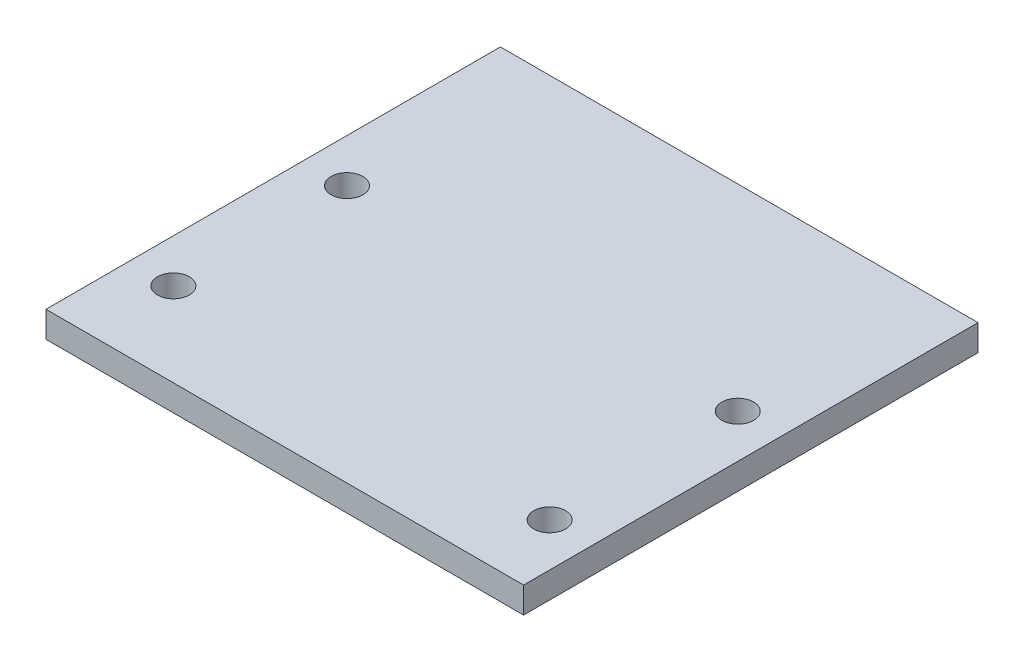
from build123d import *

# Parameters (mm, degrees)
SKETCH5_W      = 41.91
SKETCH5_H      = 39.878
SKETCH5_R      = 1.397
EXTRUDE3_DEPTH = 2.286


with BuildPart() as part:
    # Sketch5 → Extrude3 (new body)
    with BuildSketch(Plane(origin=(0, 0, 0), x_dir=(1, 0, 0), z_dir=(0, 1, 0))):
        with Locations((-20.955, -19.939)):
            Rectangle(SKETCH5_W, SKETCH5_H)
        with Locations((-38.1, -17.272)):
            Circle(SKETCH5_R, mode=Mode.SUBTRACT)
        with Locations((-38.1, -32.512)):
            Circle(SKETCH5_R, mode=Mode.SUBTRACT)
        with Locations((-3.81, -33.782)):
            Circle(SKETCH5_R, mode=Mode.SUBTRACT)
        with Locations((-3.81, -17.272)):
            Circle(SKETCH5_R, mode=Mode.SUBTRACT)
    extrude(amount=EXTRUDE3_DEPTH)


solid = part.part
